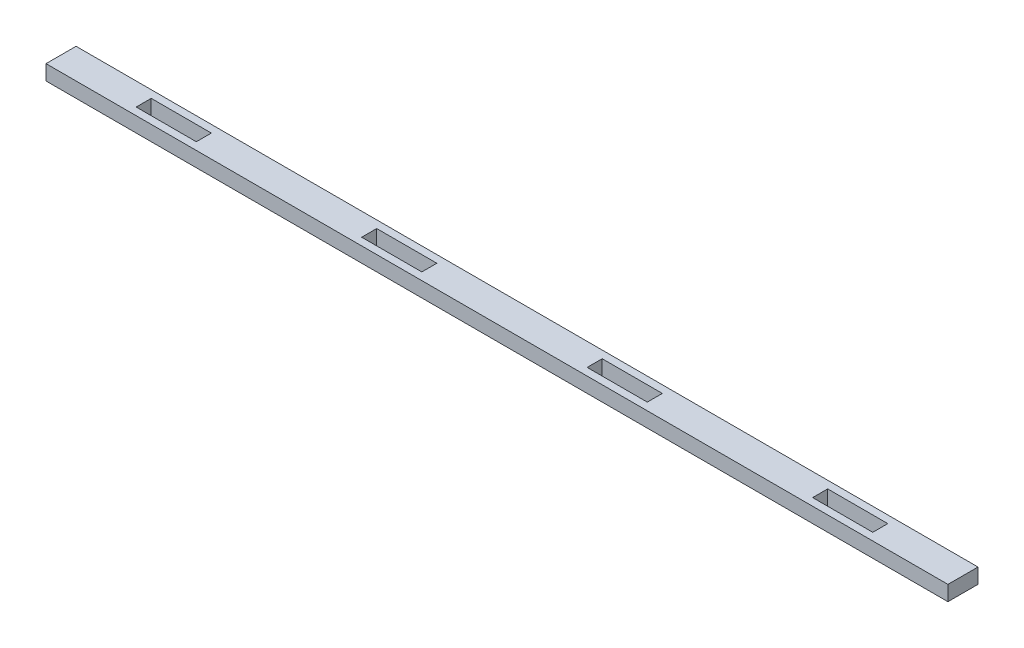
from build123d import *

# Parameters (mm, degrees)
SKETCH1_W           = 381
SKETCH1_H           = 12.7
BOSS_EXTRUDE1_DEPTH = 6.35
SKETCH2_W           = 25.4
SKETCH2_H           = 6.35
CUT_EXTRUDE1_DEPTH  = 7.35
LPATTERN1_COUNT     = 4
LPATTERN1_PITCH     = 95.25


with BuildPart() as part:
    # Sketch1 → Boss-Extrude1 (new body)
    with BuildSketch(Plane(origin=(0, 0, 0), x_dir=(1, 0, 0), z_dir=(0, 1, 0))):
        Rectangle(SKETCH1_W, SKETCH1_H)
    extrude(amount=BOSS_EXTRUDE1_DEPTH)

    # Sketch2 → Cut-Extrude1 (cut, through all)
    with BuildSketch(Plane(origin=(0, 6.35, 0), x_dir=(1, 0, 0), z_dir=(0, 1, 0))):
        with Locations((-142.875, 0)):
            Rectangle(SKETCH2_W, SKETCH2_H)
    cut_extrude1 = extrude(amount=-CUT_EXTRUDE1_DEPTH, mode=Mode.SUBTRACT)

    # LPattern1: Cut-Extrude1 ×4
    with Locations(*[(i * LPATTERN1_PITCH, 0, 0) for i in range(1, LPATTERN1_COUNT)]):
        add(cut_extrude1, mode=Mode.SUBTRACT)


solid = part.part
